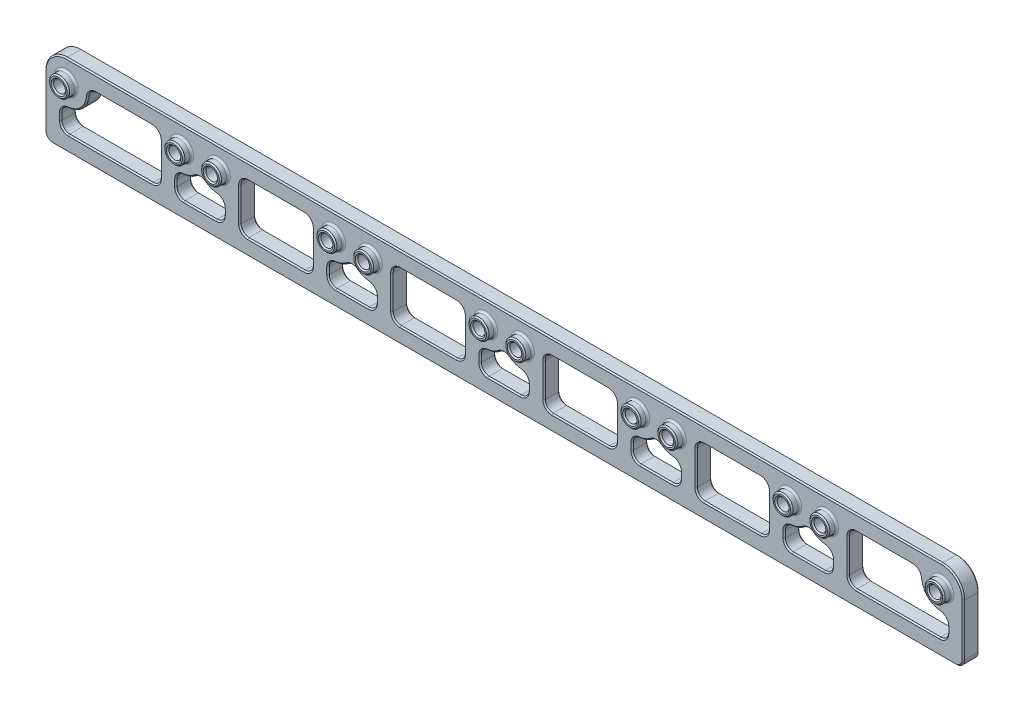
from build123d import *

# Parameters (mm, degrees)
SKETCH1_W                       = 184.15
SKETCH1_H                       = 16.3195
BOSS_EXTRUDE1_DEPTH             = 1.5875
SKETCH2_R                       = 2.00025
BOSS_EXTRUDE2_DEPTH             = 1.5875
F_3_32_0_09375_DIAMETER_HOLE1_D = 2.38125
CUT_EXTRUDE1_DEPTH              = 4.175
CUT_EXTRUDE1_DEPTH_BACK         = 2.5875
FILLET1_R                       = 0.396875
FILLET2_R                       = 1.5875
CHAMFER2_SIZE                   = 0.254


with BuildPart() as part:
    # Sketch1 → Boss-Extrude1 (new body, symmetric)
    with BuildSketch(Plane.XY):
        with Locations((0, -3.83921)):
            Rectangle(SKETCH1_W, SKETCH1_H)
    extrude(amount=BOSS_EXTRUDE1_DEPTH, both=True)

    # Sketch2 → Boss-Extrude2 (add)
    with BuildSketch(Plane.XY.offset(1.5875)):
        with Locations((-87.754460008, 0)):
            Circle(SKETCH2_R)
        with Locations((-64.645540008, 0)):
            Circle(SKETCH2_R)
        with Locations((-57.274460008, 0)):
            Circle(SKETCH2_R)
        with Locations((-34.16554, 0)):
            Circle(SKETCH2_R)
        with Locations((-26.79446, 0)):
            Circle(SKETCH2_R)
        with Locations((-3.68554, 0)):
            Circle(SKETCH2_R)
        with Locations((3.68554, 0)):
            Circle(SKETCH2_R)
        with Locations((26.79446, 0)):
            Circle(SKETCH2_R)
        with Locations((34.16554, 0)):
            Circle(SKETCH2_R)
        with Locations((57.27446, 0)):
            Circle(SKETCH2_R)
        with Locations((64.64554, 0)):
            Circle(SKETCH2_R)
        with Locations((87.75446, 0)):
            Circle(SKETCH2_R)
    extrude(amount=BOSS_EXTRUDE2_DEPTH)

    # 3/32 (0.09375) Diameter Hole1 (through all)
    with Locations(Plane.XY.offset(3.175)):
        with Locations((-87.754460008, 0), (-64.645540008, 0), (-57.274460008, 0), (-34.16554, 0), (-26.79446, 0), (-3.68554, 0), (3.68554, 0), (26.79446, 0), (34.16554, 0), (57.27446, 0), (64.64554, 0), (87.75446, 0)):
            Hole(F_3_32_0_09375_DIAMETER_HOLE1_D / 2)

    # Sketch5 → Cut-Extrude1 (cut, two sides)
    with BuildSketch(Plane.XY) as cut_extrude1_sk:
        with BuildLine():
            Line((-83.584389529, 1.1303), (-68.815610487, 1.1303))
            ThreePointArc((-68.815610487, 1.1303), (-68.928297426, 0.570135766), (-68.966080008, 0))
            Line((-68.966080008, 0), (-68.966080008, -8.80872))
            Line((-68.966080008, -8.80872), (-88.88476, -8.80872))
            Line((-88.88476, -8.80872), (-88.88476, -4.170070481))
            ThreePointArc((-88.88476, -4.170070481), (-84.699376873, -3.055083129), (-83.584389529, 1.1303))
        make_face()
        with BuildLine():
            Line((-53.104389529, 1.1303), (-38.335610479, 1.1303))
            ThreePointArc((-38.335610479, 1.1303), (-38.448297418, 0.570135766), (-38.48608, 0))
            Line((-38.48608, 0), (-38.48608, -8.80872))
            Line((-38.48608, -8.80872), (-52.953920008, -8.80872))
            Line((-52.953920008, -8.80872), (-52.953920008, 0))
            ThreePointArc((-52.953920008, 0), (-52.99170259, 0.570135766), (-53.104389529, 1.1303))
        make_face()
        with BuildLine():
            Line((-22.624389521, 1.1303), (-7.855610479, 1.1303))
            ThreePointArc((-7.855610479, 1.1303), (-7.968297418, 0.570135766), (-8.00608, 0))
            Line((-8.00608, 0), (-8.00608, -8.80872))
            Line((-8.00608, -8.80872), (-22.47392, -8.80872))
            Line((-22.47392, -8.80872), (-22.47392, 0))
            ThreePointArc((-22.47392, 0), (-22.511702582, 0.570135766), (-22.624389521, 1.1303))
        make_face()
        with BuildLine():
            Line((7.855610479, 1.1303), (22.624389521, 1.1303))
            ThreePointArc((22.624389521, 1.1303), (22.511702582, 0.570135766), (22.47392, 0))
            Line((22.47392, 0), (22.47392, -8.80872))
            Line((22.47392, -8.80872), (8.00608, -8.80872))
            Line((8.00608, -8.80872), (8.00608, 0))
            ThreePointArc((8.00608, 0), (7.968297418, 0.570135766), (7.855610479, 1.1303))
        make_face()
        with BuildLine():
            Line((38.335610479, 1.1303), (53.104389521, 1.1303))
            ThreePointArc((53.104389521, 1.1303), (52.991702582, 0.570135766), (52.95392, 0))
            Line((52.95392, 0), (52.95392, -8.80872))
            Line((52.95392, -8.80872), (38.48608, -8.80872))
            Line((38.48608, -8.80872), (38.48608, 0))
            ThreePointArc((38.48608, 0), (38.448297418, 0.570135766), (38.335610479, 1.1303))
        make_face()
        with BuildLine():
            Line((68.815610479, 1.1303), (83.584389521, 1.1303))
            ThreePointArc((83.584389521, 1.1303), (84.699376868, -3.055083132), (88.88476, -4.170070479))
            Line((88.88476, -4.170070479), (88.88476, -8.80872))
            Line((88.88476, -8.80872), (68.96608, -8.80872))
            Line((68.96608, -8.80872), (68.96608, 0))
            ThreePointArc((68.96608, 0), (68.928297418, 0.570135766), (68.815610479, 1.1303))
        make_face()
        with BuildLine():
            Line((-65.775840008, -4.170070479), (-65.775840008, -8.80872))
            Line((-65.775840008, -8.80872), (-56.144160008, -8.80872))
            Line((-56.144160008, -8.80872), (-56.144160008, -4.170070479))
            ThreePointArc((-56.144160008, -4.170070479), (-58.871154658, -4.014677084), (-60.960000008, -2.254741848))
            ThreePointArc((-60.960000008, -2.254741848), (-63.048845358, -4.014677084), (-65.775840008, -4.170070479))
        make_face()
        with BuildLine():
            Line((-35.29584, -4.170070479), (-35.29584, -8.80872))
            Line((-35.29584, -8.80872), (-25.66416, -8.80872))
            Line((-25.66416, -8.80872), (-25.66416, -4.170070479))
            ThreePointArc((-25.66416, -4.170070479), (-28.39115465, -4.014677084), (-30.48, -2.254741848))
            ThreePointArc((-30.48, -2.254741848), (-32.56884535, -4.014677084), (-35.29584, -4.170070479))
        make_face()
        with BuildLine():
            Line((-4.81584, -4.170070479), (-4.81584, -8.80872))
            Line((-4.81584, -8.80872), (4.81584, -8.80872))
            Line((4.81584, -8.80872), (4.81584, -4.170070479))
            ThreePointArc((4.81584, -4.170070479), (2.08884535, -4.014677084), (0, -2.254741848))
            ThreePointArc((0, -2.254741848), (-2.08884535, -4.014677084), (-4.81584, -4.170070479))
        make_face()
        with BuildLine():
            Line((25.66416, -4.170070479), (25.66416, -8.80872))
            Line((25.66416, -8.80872), (35.29584, -8.80872))
            Line((35.29584, -8.80872), (35.29584, -4.170070479))
            ThreePointArc((35.29584, -4.170070479), (32.56884535, -4.014677084), (30.48, -2.254741848))
            ThreePointArc((30.48, -2.254741848), (28.39115465, -4.014677084), (25.66416, -4.170070479))
        make_face()
        with BuildLine():
            Line((56.14416, -4.170070479), (56.14416, -8.80872))
            Line((56.14416, -8.80872), (65.77584, -8.80872))
            Line((65.77584, -8.80872), (65.77584, -4.170070479))
            ThreePointArc((65.77584, -4.170070479), (63.04884535, -4.014677084), (60.96, -2.254741848))
            ThreePointArc((60.96, -2.254741848), (58.87115465, -4.014677084), (56.14416, -4.170070479))
        make_face()
        with BuildLine():
            Line((-92.075, 0), (-92.075, 4.32054))
            Line((-92.075, 4.32054), (-87.754460008, 4.32054))
            ThreePointArc((-87.754460008, 4.32054), (-90.80954314, 3.055083132), (-92.075, 0))
        make_face()
        with BuildLine():
            Line((87.75446, 4.32054), (92.075, 4.32054))
            Line((92.075, 4.32054), (92.075, 0))
            ThreePointArc((92.075, 0), (90.809543132, 3.055083132), (87.75446, 4.32054))
        make_face()
    extrude(amount=CUT_EXTRUDE1_DEPTH, mode=Mode.SUBTRACT)
    extrude(cut_extrude1_sk.sketch, amount=-CUT_EXTRUDE1_DEPTH_BACK, mode=Mode.SUBTRACT)

    # Fillet1
    fillet1_edges = [part.edges().sort_by_distance(p)[0] for p in [
        (-89.754710008, 0, 1.5875),
        (-66.645790008, 0, 1.5875),
        (-59.274710008, 0, 1.5875),
        (-36.16579, 0, 1.5875),
        (-28.79471, 0, 1.5875),
        (-5.68579, 0, 1.5875),
        (1.68529, 0, 1.5875),
        (24.79421, 0, 1.5875),
        (32.16529, 0, 1.5875),
        (55.27421, 0, 1.5875),
        (62.64529, 0, 1.5875),
        (85.75421, 0, 1.5875),
    ]]
    fillet(fillet1_edges, radius=FILLET1_R)

    # Fillet2
    fillet2_edges = [part.edges().sort_by_distance(p)[0] for p in [
        (-92.075, -11.99896, 0),
        (92.075, -11.99896, 0),
        (88.88476, -8.80872, 0),
        (88.88476, -4.170070479, 0),
        (83.584389521, 1.1303, 0),
        (68.815610479, 1.1303, 0),
        (68.96608, -8.80872, 0),
        (65.77584, -8.80872, 0),
        (56.14416, -8.80872, 0),
        (56.14416, -4.170070479, 0),
        (60.96, -2.254741848, 0),
        (53.104389521, 1.1303, 0),
        (38.335610479, 1.1303, 0),
        (38.48608, -8.80872, 0),
        (52.95392, -8.80872, 0),
        (35.29584, -8.80872, 0),
        (35.29584, -4.170070479, 0),
        (30.48, -2.254741848, 0),
        (25.66416, -4.170070479, 0),
        (25.66416, -8.80872, 0),
        (22.47392, -8.80872, 0),
        (22.624389521, 1.1303, 0),
        (7.855610479, 1.1303, 0),
        (8.00608, -8.80872, 0),
        (4.81584, -8.80872, 0),
        (4.81584, -4.170070479, 0),
        (0, -2.254741848, 0),
        (-4.81584, -4.170070479, 0),
        (-4.81584, -8.80872, 0),
        (-8.00608, -8.80872, 0),
        (-22.47392, -8.80872, 0),
        (-22.624389521, 1.1303, 0),
        (-7.855610479, 1.1303, 0),
        (-25.66416, -8.80872, 0),
        (-25.66416, -4.170070479, 0),
        (-30.48, -2.254741848, 0),
        (-35.29584, -4.170070479, 0),
        (-35.29584, -8.80872, 0),
        (-38.335610479, 1.1303, 0),
        (-38.48608, -8.80872, 0),
        (-52.953920008, -8.80872, 0),
        (-53.104389529, 1.1303, 0),
        (-56.144160008, -8.80872, 0),
        (-56.144160008, -4.170070479, 0),
        (-60.960000008, -2.254741848, 0),
        (-65.775840008, -4.170070479, 0),
        (-65.775840008, -8.80872, 0),
        (-68.966080008, -8.80872, 0),
        (-68.815610487, 1.1303, 0),
        (-88.88476, -8.80872, 0),
        (-88.88476, -4.170070481, 0),
        (-83.584389529, 1.1303, 0),
        (65.77584, -4.170070479, 0),
    ]]
    fillet(fillet2_edges, radius=FILLET2_R)

    # Chamfer2
    chamfer2_edges = [part.edges().sort_by_distance(p)[0] for p in [
        (-25.603835, 0, 3.175),
        (-25.603835, 0, -1.5875),
        (-32.974915, 0, 3.175),
        (-32.974915, 0, -1.5875),
        (-56.083835008, 0, 3.175),
        (-56.083835008, 0, -1.5875),
        (-63.454915008, 0, 3.175),
        (-63.454915008, 0, -1.5875),
        (-86.563835008, 0, 3.175),
        (-86.563835008, 0, -1.5875),
        (-92.075, -5.20573, 1.5875),
        (-4e-09, 4.32054, 1.5875),
        (-90.809543139, 3.055083134, 1.5875),
        (90.809543132, 3.055083132, 1.5875),
        (-89.754710008, 0, 3.175),
        (-4e-09, 4.32054, -1.5875),
        (-92.075, -5.20573, -1.5875),
        (-66.645790008, 0, 3.175),
        (-59.274710008, 0, 3.175),
        (-36.16579, 0, 3.175),
        (-28.79471, 0, 3.175),
        (90.809543132, 3.055083132, -1.5875),
        (-90.809543139, 3.055083134, -1.5875),
        (-5.68579, 0, 3.175),
        (1.68529, 0, 3.175),
        (24.79421, 0, 3.175),
        (32.16529, 0, 3.175),
        (55.27421, 0, 3.175),
        (63.060871288, -4.019439136, -1.5875),
        (63.060871288, -4.019439136, 1.5875),
        (65.77584, -6.55577149, -1.5875),
        (65.77584, -6.55577149, 1.5875),
        (0, -11.99896, -1.5875),
        (0, -11.99896, 1.5875),
        (8.00608, -3.83921, -1.5875),
        (15.24, -8.80872, -1.5875),
        (22.47392, -3.83921, -1.5875),
        (15.24, 1.1303, -1.5875),
        (-22.47392, -3.83921, -1.5875),
        (-15.24, -8.80872, -1.5875),
        (-8.00608, -3.83921, -1.5875),
        (-15.24, 1.1303, -1.5875),
        (-52.953920008, -3.83921, -1.5875),
        (-45.720000004, -8.80872, -1.5875),
        (-38.48608, -3.83921, -1.5875),
        (-45.720000004, 1.1303, -1.5875),
        (-84.699376873, -3.05508313, -1.5875),
        (62.64529, 0, 3.175),
        (-88.88476, -6.555771489, -1.5875),
        (-78.925420004, -8.80872, -1.5875),
        (-68.966080008, -3.83921, -1.5875),
        (-76.208858518, 1.1303, -1.5875),
        (58.859128712, -4.019439136, -1.5875),
        (56.14416, -6.55577149, -1.5875),
        (60.96, -8.80872, -1.5875),
        (28.379128712, -4.019439136, -1.5875),
        (25.66416, -6.55577149, -1.5875),
        (30.48, -8.80872, -1.5875),
        (35.29584, -6.55577149, -1.5875),
        (32.580871288, -4.019439136, -1.5875),
        (-2.100871288, -4.019439136, -1.5875),
        (-4.81584, -6.55577149, -1.5875),
        (0, -8.80872, -1.5875),
        (4.81584, -6.55577149, -1.5875),
        (2.100871288, -4.019439136, -1.5875),
        (-32.580871288, -4.019439136, -1.5875),
        (-35.29584, -6.55577149, -1.5875),
        (-30.48, -8.80872, -1.5875),
        (-25.66416, -6.55577149, -1.5875),
        (-28.379128712, -4.019439136, -1.5875),
        (92.075, -5.20573, -1.5875),
        (68.96608, -3.83921, -1.5875),
        (78.92542, -8.80872, -1.5875),
        (88.88476, -6.55577149, -1.5875),
        (84.699376868, -3.055083132, -1.5875),
        (76.20885851, 1.1303, -1.5875),
        (38.48608, -3.83921, -1.5875),
        (45.72, -8.80872, -1.5875),
        (52.95392, -3.83921, -1.5875),
        (45.72, 1.1303, -1.5875),
        (-63.060871296, -4.019439136, -1.5875),
        (-65.775840008, -6.55577149, -1.5875),
        (-60.960000008, -8.80872, -1.5875),
        (-56.144160008, -6.55577149, -1.5875),
        (-58.85912872, -4.019439136, -1.5875),
        (91.610032015, -11.533992015, -1.5875),
        (-91.610032015, -11.533992015, -1.5875),
        (8.00608, -3.83921, 1.5875),
        (15.24, 1.1303, 1.5875),
        (22.47392, -3.83921, 1.5875),
        (15.24, -8.80872, 1.5875),
        (-22.47392, -3.83921, 1.5875),
        (-15.24, 1.1303, 1.5875),
        (-8.00608, -3.83921, 1.5875),
        (-15.24, -8.80872, 1.5875),
        (-52.953920008, -3.83921, 1.5875),
        (-45.720000004, 1.1303, 1.5875),
        (-38.48608, -3.83921, 1.5875),
        (-45.720000004, -8.80872, 1.5875),
        (-88.88476, -6.555771489, 1.5875),
        (-84.699376873, -3.05508313, 1.5875),
        (-76.208858518, 1.1303, 1.5875),
        (85.75421, 0, 3.175),
        (-68.966080008, -3.83921, 1.5875),
        (-78.925420004, -8.80872, 1.5875),
        (56.14416, -6.55577149, 1.5875),
        (58.859128712, -4.019439136, 1.5875),
        (60.96, -8.80872, 1.5875),
        (25.66416, -6.55577149, 1.5875),
        (28.379128712, -4.019439136, 1.5875),
        (32.580871288, -4.019439136, 1.5875),
        (35.29584, -6.55577149, 1.5875),
        (30.48, -8.80872, 1.5875),
        (-4.81584, -6.55577149, 1.5875),
        (-2.100871288, -4.019439136, 1.5875),
        (2.100871288, -4.019439136, 1.5875),
        (4.81584, -6.55577149, 1.5875),
        (0, -8.80872, 1.5875),
        (-35.29584, -6.55577149, 1.5875),
        (-32.580871288, -4.019439136, 1.5875),
        (-28.379128712, -4.019439136, 1.5875),
        (-25.66416, -6.55577149, 1.5875),
        (-30.48, -8.80872, 1.5875),
        (68.96608, -3.83921, 1.5875),
        (76.20885851, 1.1303, 1.5875),
        (84.699376868, -3.055083132, 1.5875),
        (88.88476, -6.55577149, 1.5875),
        (78.92542, -8.80872, 1.5875),
        (38.48608, -3.83921, 1.5875),
        (45.72, 1.1303, 1.5875),
        (52.95392, -3.83921, 1.5875),
        (45.72, -8.80872, 1.5875),
        (-65.775840008, -6.55577149, 1.5875),
        (-63.060871296, -4.019439136, 1.5875),
        (-58.85912872, -4.019439136, 1.5875),
        (-56.144160008, -6.55577149, 1.5875),
        (-60.960000008, -8.80872, 1.5875),
        (92.075, -5.20573, 1.5875),
        (91.610032015, -11.533992015, 1.5875),
        (-91.610032015, -11.533992015, 1.5875),
        (65.353496908, -4.812099612, 1.5875),
        (65.353496908, -4.812099612, -1.5875),
        (88.419792015, -8.343752015, 1.5875),
        (88.419792015, -8.343752015, -1.5875),
        (88.462416908, -4.812099612, 1.5875),
        (88.462416908, -4.812099612, -1.5875),
        (82.942360388, 0.707956908, 1.5875),
        (82.942360388, 0.707956908, -1.5875),
        (69.431047985, 0.665332015, 1.5875),
        (69.431047985, 0.665332015, -1.5875),
        (69.431047985, -8.343752015, 1.5875),
        (69.431047985, -8.343752015, -1.5875),
        (65.310872015, -8.343752015, 1.5875),
        (65.310872015, -8.343752015, -1.5875),
        (56.609127985, -8.343752015, 1.5875),
        (56.609127985, -8.343752015, -1.5875),
        (56.566503092, -4.812099612, 1.5875),
        (56.566503092, -4.812099612, -1.5875),
        (60.96, -3.030046053, 1.5875),
        (60.96, -3.030046053, -1.5875),
        (52.488952015, 0.665332015, 1.5875),
        (52.488952015, 0.665332015, -1.5875),
        (38.951047985, 0.665332015, 1.5875),
        (38.951047985, 0.665332015, -1.5875),
        (38.951047985, -8.343752015, 1.5875),
        (38.951047985, -8.343752015, -1.5875),
        (52.488952015, -8.343752015, 1.5875),
        (52.488952015, -8.343752015, -1.5875),
        (34.830872015, -8.343752015, 1.5875),
        (34.830872015, -8.343752015, -1.5875),
        (34.873496908, -4.812099612, 1.5875),
        (34.873496908, -4.812099612, -1.5875),
        (30.48, -3.030046053, 1.5875),
        (30.48, -3.030046053, -1.5875),
        (26.086503092, -4.812099612, 1.5875),
        (26.086503092, -4.812099612, -1.5875),
        (26.129127985, -8.343752015, 1.5875),
        (26.129127985, -8.343752015, -1.5875),
        (22.008952015, -8.343752015, 1.5875),
        (22.008952015, -8.343752015, -1.5875),
        (22.008952015, 0.665332015, 1.5875),
        (22.008952015, 0.665332015, -1.5875),
        (8.471047985, 0.665332015, 1.5875),
        (8.471047985, 0.665332015, -1.5875),
        (8.471047985, -8.343752015, 1.5875),
        (8.471047985, -8.343752015, -1.5875),
        (4.350872015, -8.343752015, 1.5875),
        (4.350872015, -8.343752015, -1.5875),
        (4.393496908, -4.812099612, 1.5875),
        (4.393496908, -4.812099612, -1.5875),
        (0, -3.030046053, 1.5875),
        (0, -3.030046053, -1.5875),
        (-4.393496908, -4.812099612, 1.5875),
        (-4.393496908, -4.812099612, -1.5875),
        (-4.350872015, -8.343752015, 1.5875),
        (-4.350872015, -8.343752015, -1.5875),
        (-8.471047985, -8.343752015, 1.5875),
        (-8.471047985, -8.343752015, -1.5875),
        (-22.008952015, -8.343752015, 1.5875),
        (-22.008952015, -8.343752015, -1.5875),
        (-22.008952015, 0.665332015, 1.5875),
        (-22.008952015, 0.665332015, -1.5875),
        (-8.471047985, 0.665332015, 1.5875),
        (-8.471047985, 0.665332015, -1.5875),
        (-26.129127985, -8.343752015, 1.5875),
        (-26.129127985, -8.343752015, -1.5875),
        (-26.086503092, -4.812099612, 1.5875),
        (-26.086503092, -4.812099612, -1.5875),
        (-30.48, -3.030046053, 1.5875),
        (-30.48, -3.030046053, -1.5875),
        (-34.873496908, -4.812099612, 1.5875),
        (-34.873496908, -4.812099612, -1.5875),
        (-34.830872015, -8.343752015, 1.5875),
        (-34.830872015, -8.343752015, -1.5875),
        (-38.951047985, 0.665332015, 1.5875),
        (-38.951047985, 0.665332015, -1.5875),
        (-38.951047985, -8.343752015, 1.5875),
        (-38.951047985, -8.343752015, -1.5875),
        (-52.488952023, -8.343752015, 1.5875),
        (-52.488952023, -8.343752015, -1.5875),
        (-52.488952023, 0.665332015, 1.5875),
        (-52.488952023, 0.665332015, -1.5875),
        (-56.609127993, -8.343752015, 1.5875),
        (-56.609127993, -8.343752015, -1.5875),
        (-56.5665031, -4.812099612, 1.5875),
        (-56.5665031, -4.812099612, -1.5875),
        (-60.960000008, -3.030046053, 1.5875),
        (-60.960000008, -3.030046053, -1.5875),
        (-65.353496916, -4.812099612, 1.5875),
        (-65.353496916, -4.812099612, -1.5875),
        (-65.310872023, -8.343752015, 1.5875),
        (-65.310872023, -8.343752015, -1.5875),
        (-69.431047993, -8.343752015, 1.5875),
        (-69.431047993, -8.343752015, -1.5875),
        (-69.431047993, 0.665332015, 1.5875),
        (-69.431047993, 0.665332015, -1.5875),
        (-88.419792015, -8.343752015, 1.5875),
        (-88.419792015, -8.343752015, -1.5875),
        (-88.462416908, -4.812099612, 1.5875),
        (-88.462416908, -4.812099612, -1.5875),
        (-82.942360396, 0.707956908, 1.5875),
        (-82.942360396, 0.707956908, -1.5875),
        (88.945085, 0, 3.175),
        (88.945085, 0, -1.5875),
        (65.836165, 0, 3.175),
        (65.836165, 0, -1.5875),
        (58.465085, 0, 3.175),
        (58.465085, 0, -1.5875),
        (35.356165, 0, 3.175),
        (35.356165, 0, -1.5875),
        (27.985085, 0, 3.175),
        (27.985085, 0, -1.5875),
        (4.876165, 0, 3.175),
        (4.876165, 0, -1.5875),
        (-2.494915, 0, 3.175),
        (-2.494915, 0, -1.5875),
    ]]
    chamfer(chamfer2_edges, length=CHAMFER2_SIZE)


solid = part.part
